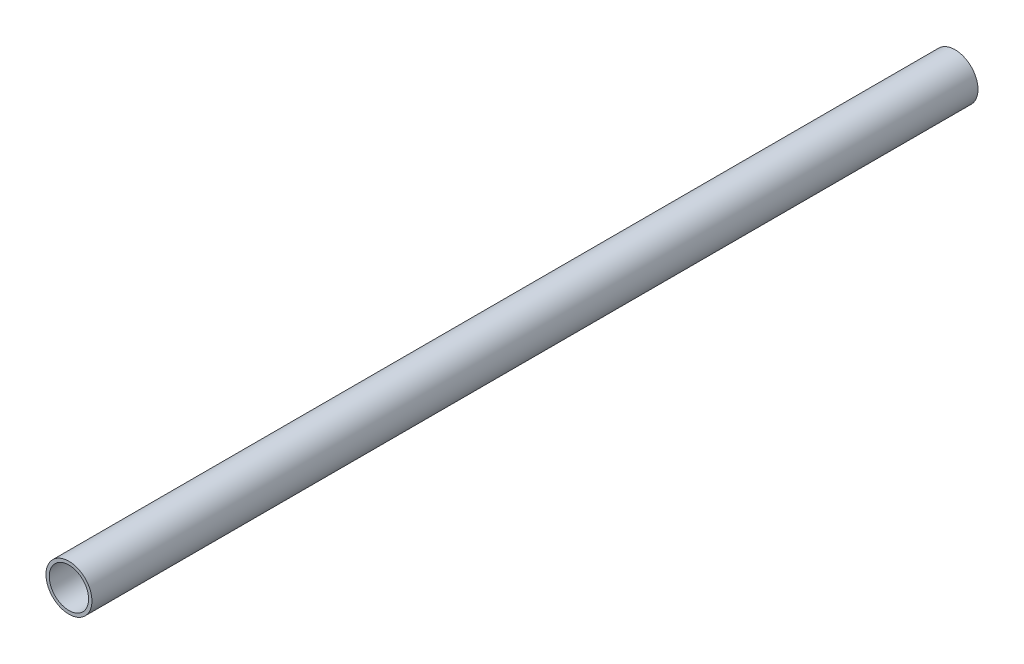
from build123d import *

# Parameters (mm, degrees)
SKETCH1_R           = 7
BOSS_EXTRUDE1_DEPTH = 270
SKETCH2_R           = 6
CUT_EXTRUDE1_DEPTH  = 271


with BuildPart() as part:
    # Sketch1 → Boss-Extrude1 (new body)
    with BuildSketch(Plane.XY):
        Circle(SKETCH1_R)
    extrude(amount=BOSS_EXTRUDE1_DEPTH)

    # Sketch2 → Cut-Extrude1 (cut, through all)
    with BuildSketch(Plane.XY.offset(270)):
        Circle(SKETCH2_R)
    extrude(amount=-CUT_EXTRUDE1_DEPTH, mode=Mode.SUBTRACT)


solid = part.part
